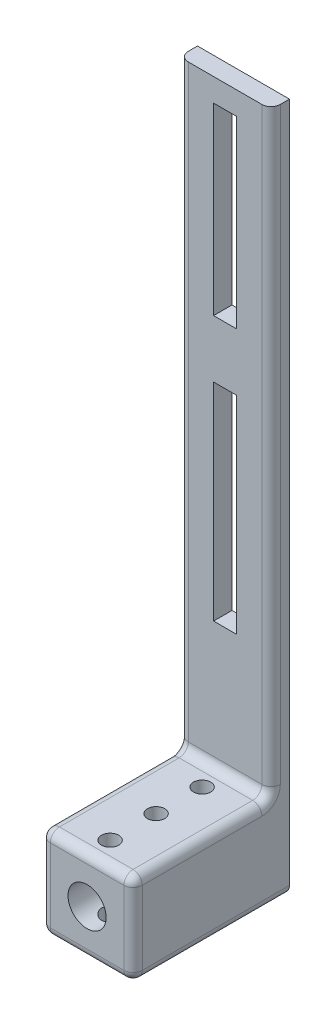
from build123d import *

# Parameters (mm, degrees)
CROQUIS1_W              = 20
CROQUIS1_H              = 150
CROQUIS1_R              = 4.15
CROQUIS1_W_2            = 5
CROQUIS1_H_2            = 40
CROQUIS1_H_3            = 45
SALIENTE_EXTRUIR1_DEPTH = 4
SALIENTE_EXTRUIR2_START = 4
CROQUIS2_W              = 20
CROQUIS2_H              = 20
CROQUIS2_R              = 4.15
SALIENTE_EXTRUIR2_DEPTH = 30
REDONDEO1_R             = 2
CROQUIS3_R              = 1.875
CORTAR_EXTRUIR1_DEPTH   = 20


with BuildPart() as part:
    # Croquis1 → Saliente-Extruir1 (new body)
    with BuildSketch(Plane.XY):
        with Locations((0, 75)):
            Rectangle(CROQUIS1_W, CROQUIS1_H)
        with Locations((0, 10)):
            Circle(CROQUIS1_R, mode=Mode.SUBTRACT)
        with Locations((0, 125)):
            Rectangle(CROQUIS1_W_2, CROQUIS1_H_2, mode=Mode.SUBTRACT)
        with Locations((0, 70)):
            Rectangle(CROQUIS1_W_2, CROQUIS1_H_3, mode=Mode.SUBTRACT)
    extrude(amount=SALIENTE_EXTRUIR1_DEPTH)

    # Croquis2 → Saliente-Extruir2 (add)
    with BuildSketch(Plane.XY.offset(SALIENTE_EXTRUIR2_START)):
        with Locations((0, 10)):
            Rectangle(CROQUIS2_W, CROQUIS2_H)
        with Locations((0, 10)):
            Circle(CROQUIS2_R, mode=Mode.SUBTRACT)
    extrude(amount=SALIENTE_EXTRUIR2_DEPTH)

    # Redondeo1
    redondeo1_edges = [part.edges().sort_by_distance(p)[0] for p in [
        (-10, 85, 4),
        (10, 85, 4),
        (0, 20, 4),
        (10, 10, 34),
        (0, 20, 34),
        (10, 20, 19),
        (-10, 10, 34),
        (-10, 20, 19),
        (0, 0, 34),
        (10, 0, 17),
        (-10, 0, 17),
    ]]
    fillet(redondeo1_edges, radius=REDONDEO1_R)

    # Croquis3 → Cortar-Extruir1 (cut)
    with BuildSketch(Plane(origin=(0, 0, 0), x_dir=(1, 0, 0), z_dir=(0, 1, 0))):
        with Locations((0, -9)):
            Circle(CROQUIS3_R)
        with Locations((0, -29)):
            Circle(CROQUIS3_R)
        with Locations((0, -19)):
            Circle(CROQUIS3_R)
    extrude(amount=CORTAR_EXTRUIR1_DEPTH, mode=Mode.SUBTRACT)


solid = part.part
